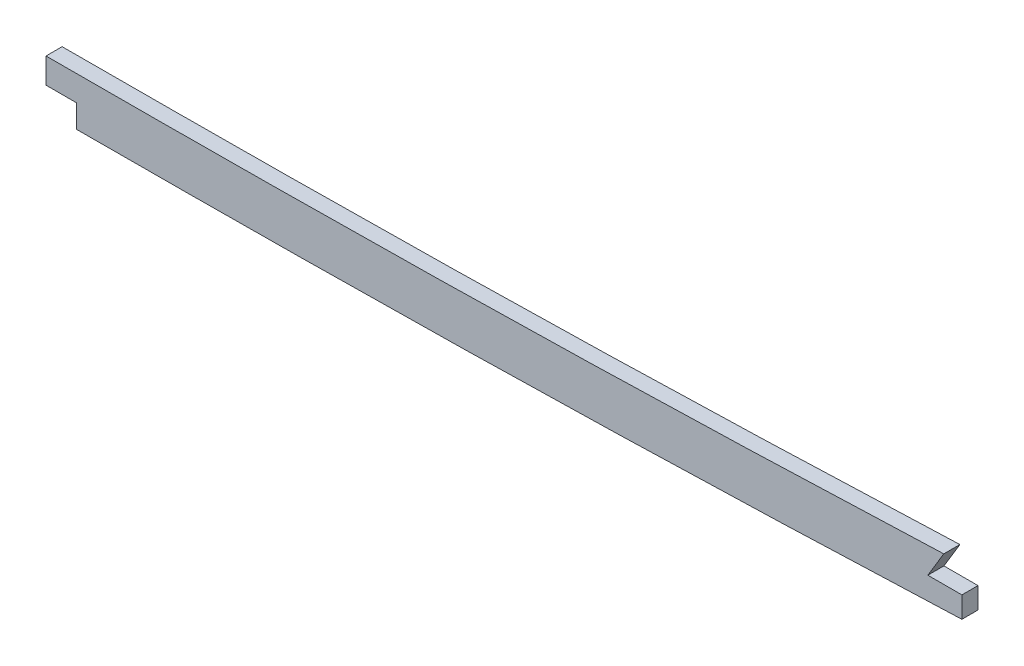
from build123d import *

# Parameters (mm, degrees)
BOSS_EXTRUDE1_DEPTH = 3.175
CUT_EXTRUDE1_DEPTH  = 7.3500001
FILLET1_R           = 2.54
CUT_EXTRUDE2_DEPTH  = 7.62


with BuildPart() as part:
    # Sketch1 → Boss-Extrude1 (new body, symmetric)
    with BuildSketch(Plane.XY):
        with BuildLine():
            Line((499.61002795, -53.470702797), (1046.28548189, -53.470702797))
            add(Edge.make_bspline(
                [(2669.54, -9.569049356), (2615.393603553, -13.17073937), (2561.080658619, -16.536108081), (2506.205230446, -19.758621957), (2430.209106802, -23.505211705), (2354.212983157, -26.631486423), (2332.570330468, -27.480988169), (2156.268639429, -34.377768543), (1979.966947376, -41.628631248), (1824.114277635, -52.771265877), (1636.928606778, -53.579569849), (1449.742935921, -53.454024613), (1418.006730935, -53.470702797), (1324.899336146, -53.470702797), (1231.791940344, -53.470702797), (1170.441269319, -53.470702797), (1108.784075813, -53.470702797), (1047.126882346, -53.470702797), (1046.846414188, -53.470702797), (1046.565947184, -53.470702797), (1046.28548189, -53.470702797)],
                knots=[103.698913506, 103.698913506, 103.698913506, 103.698913506, 103.698913506, 103.698913506, 130.927896619, 130.927896619, 130.927896619, 141.337054719, 141.337054719, 141.337054719, 218.101815019, 218.101815019, 218.101815019, 233.772059419, 233.772059419, 233.772059419, 264.077723219, 264.077723219, 264.077723219, 264.2162088, 264.2162088, 264.2162088, 264.2162088, 264.2162088, 264.2162088], degree=5))
            Line((2669.54, -9.569049356), (2669.54, 9.5231025))
            add(Edge.make_bspline(
                [(2669.54, 9.5231025), (2667.126494524, 9.36235515), (2659.861586685, 8.880281494), (2635.666282302, 7.292469146), (2596.857665529, 4.826056853), (2545.729743039, 1.758344093), (2494.405305707, -1.098555235), (2451.533022267, -3.266573297), (2417.198316756, -4.86708361), (2391.457076919, -6.003589235), (2365.634736307, -7.086854581), (2339.546284672, -8.137729944), (2313.466132974, -9.165138371), (2287.612375486, -10.179478215), (2261.763347437, -11.201032297), (2227.285329715, -12.583842557), (2184.175569393, -14.36607236), (2132.429066114, -16.607427868), (2063.4255234, -19.708920485), (1977.174907635, -23.700543313), (1873.732451432, -28.149389221), (1770.37461881, -31.657468649), (1667.085687813, -33.793117556), (1581.011094491, -34.383188831), (1512.07397126, -34.4278026), (1443.061513477, -34.409510402), (1356.800927879, -34.424432812), (1218.794626954, -34.418464788), (1115.289022786, -34.420702797), (1046.28548189, -34.420702797)],
                knots=[103.571582669, 103.571582669, 103.571582669, 103.571582669, 104.300777207, 105.766098403, 110.877392287, 115.98868617, 121.099980054, 126.211273938, 128.76692088, 131.322567822, 133.878214764, 136.433861706, 138.989508647, 141.545155589, 144.100802531, 146.656449473, 151.767743357, 156.879037241, 161.990331124, 172.212918892, 182.43550666, 192.658094427, 202.880682195, 213.103269962, 218.214563846, 223.32585773, 233.548445497, 243.771033265, 264.2162088, 264.2162088, 264.2162088, 264.2162088], degree=3))
            Line((1046.28548189, -34.420702797), (499.61002795, -34.420702797))
            add(Edge.make_bspline(
                [(499.61002795, -34.420702797), (488.614737518, -34.420702797), (472.236395365, -34.420702798), (449.940231846, -34.420702794), (427.771305695, -34.42070281), (405.874681663, -34.420702712), (384.584909128, -34.420702942), (368.900229326, -34.420702244), (353.376568613, -34.420704862), (332.608466435, -34.420689186), (306.287754853, -34.420570006), (274.023487704, -34.420538256), (252.271015965, -34.420709741), (241.425150134, -34.420702761)],
                knots=[19.90682951, 19.90682951, 19.90682951, 19.90682951, 23.220120017, 24.876765271, 26.533410525, 29.846701033, 31.503346286, 33.15999154, 34.816636794, 36.473282048, 39.786572556, 43.099863063, 46.413153571, 46.413153571, 46.413153571, 46.413153571], degree=3))
            add(Edge.make_bspline(
                [(241.425150134, -34.420702761), (239.394928853, -34.420701455), (235.322322927, -34.420495867), (227.274423443, -34.398702533), (217.319360062, -34.297466855), (205.530690077, -33.976385563), (189.963341914, -33.212641271), (170.696984653, -31.543495194), (147.533261232, -28.314398128), (125.482753206, -24.202109872), (109.358914834, -20.622537553), (100.964116069, -18.612521054), (99.06, -18.149327722)],
                knots=[0, 0, 0, 0, 0.622088422, 1.244176844, 2.488353689, 3.732530533, 4.976707377, 7.465061066, 9.953414755, 12.441768444, 14.55823542, 15.180323842, 15.180323842, 15.180323842, 15.180323842], degree=3))
            Line((99.06, -18.149327722), (99.06, -37.741485304))
            add(Edge.make_bspline(
                [(241.425137875, -53.470702761), (224.286916993, -53.470691732), (207.149474967, -53.467315374), (190.203897513, -52.686577078), (161.734965878, -49.987457476), (133.266034188, -45.175583375), (121.749620566, -42.910592695), (110.349390726, -40.420274627), (99.06, -37.741485304)],
                knots=[0, 0, 0, 0, 0, 0, 8.71381608, 8.71381608, 8.71381608, 14.701907176, 14.701907176, 14.701907176, 14.701907176, 14.701907176, 14.701907176], degree=5))
            add(Edge.make_bspline(
                [(499.61002795, -53.470702797), (492.136820835, -53.470702797), (484.754348064, -53.470702797), (477.443025859, -53.470702797), (448.516583145, -53.470702797), (419.590140517, -53.470702797), (398.368118521, -53.470702797), (355.647540186, -53.470702797), (312.926961851, -53.470702797), (289.235090436, -53.470293029), (265.364963651, -53.470705034), (241.4948369, -53.470702789), (241.471603891, -53.470702785), (241.448370882, -53.470702776), (241.425137875, -53.470702761)],
                knots=[19.90682951, 19.90682951, 19.90682951, 19.90682951, 19.90682951, 19.90682951, 23.637897311, 23.637897311, 23.637897311, 34.276545571, 34.276545571, 34.276545571, 46.401340901, 46.401340901, 46.401340901, 46.413153571, 46.413153571, 46.413153571, 46.413153571, 46.413153571, 46.413153571], degree=5))
        make_face()
    extrude(amount=BOSS_EXTRUDE1_DEPTH, both=True)

    # Sketch2 → Cut-Extrude1 (cut, through all)
    with BuildSketch(Plane.XY.offset(3.175)):
        with BuildLine():
            add(Edge.make_bspline(
                [(2312.9875, -9.183260037), (2304.505441691, -9.516700376), (2287.441020622, -10.186250162), (2261.763347437, -11.201032297), (2228.230552004, -12.545932515), (2203.310445107, -13.575047161), (2187.00995947, -14.263260037)],
                knots=[139.04033329, 139.04033329, 139.04033329, 139.04033329, 141.545155589, 144.100802531, 146.656449473, 151.487488909, 151.487488909, 151.487488909, 151.487488909], degree=3))
            Line((2187.00995947, -14.263260037), (2312.9875, -14.263260037))
            Line((2312.9875, -14.263260037), (2312.9875, -9.183260037))
        make_face()
    extrude(amount=-CUT_EXTRUDE1_DEPTH, mode=Mode.SUBTRACT)

    # Fillet1
    fillet1_edges = [part.edges().sort_by_distance(p)[0] for p in [
        (2669.54, -9.569049356, -1.5875),
        (2669.54, 9.5231025, -1.5875),
        (99.06, -37.741485304, -1.5875),
        (99.06, -18.149327722, -1.5875),
        (2312.9875, -9.183260037, 1.5875),
        (2312.9875, -14.263260037, 0),
    ]]
    fillet(fillet1_edges, radius=FILLET1_R)

    # Sketch3 → Cut-Extrude2 (cut)
    with BuildSketch(Plane.XY.offset(3.175)):
        Polygon((1534.520918045, -34.408934174), (1534.520918045, -44.380222694), (1546.518002564, -44.380222694), (1546.518002564, -53.444776375), (1546.518002564, -106.023211896), (55.693371554, -302.623897547), (0, 180.999666526), (1534.520918045, 89.767095142), align=None)
        Polygon((1888.274985361, -27.424617015), (1881.98614013, -37.858137115), (1895.406326502, -37.858137115), (1895.406326502, -46.204944132), (1895.406326502, -56.664358377), (2711.703422573, -53.444776375), (2711.703422573, 52.291712547), (1888.274985361, 63.130297766), align=None)
    extrude(amount=-CUT_EXTRUDE2_DEPTH, mode=Mode.SUBTRACT)


solid = part.part
